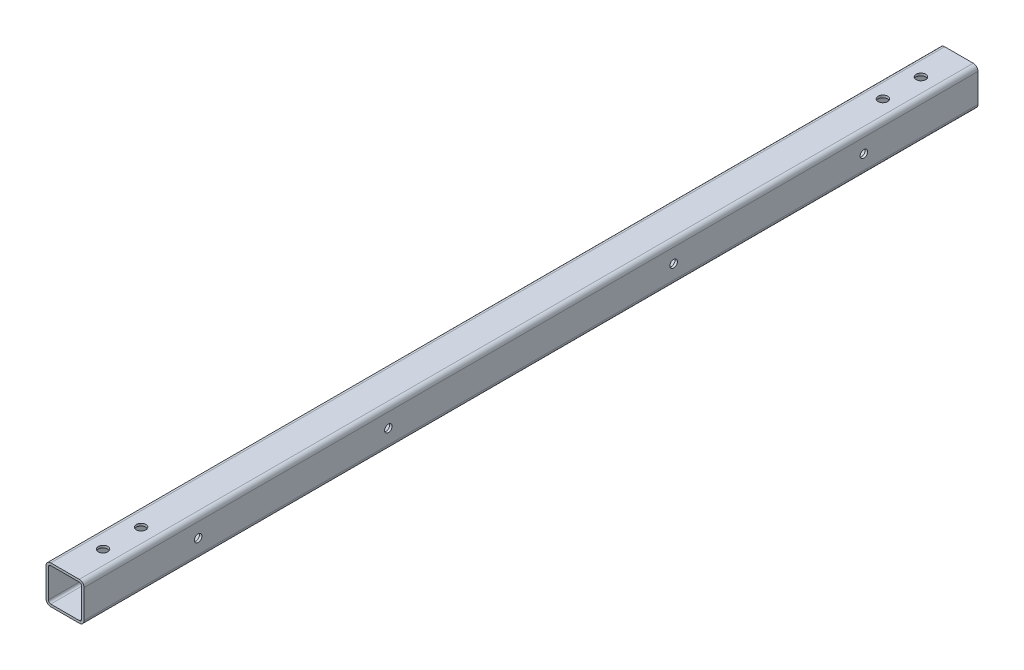
from build123d import *

# Parameters (mm, degrees)
SKETCH1_W          = 25.4
SKETCH1_H          = 25.4
BASE_EXTRUDE_DEPTH = 298.45
FILLET1_R          = 3.175
SHELL1_T           = -1.5875
SKETCH4_R          = 3.175
CUT_EXTRUDE1_DEPTH = 26.4
CUT_EXTRUDE3_REACH = 3.588
SKETCH6_R          = 2.5


with BuildPart() as part:
    # Sketch1 → Base-Extrude (new body, symmetric)
    with BuildSketch(Plane.XY):
        Rectangle(SKETCH1_W, SKETCH1_H)
    extrude(amount=BASE_EXTRUDE_DEPTH, both=True)

    # Fillet1
    fillet1_edges = [part.edges().sort_by_distance(p)[0] for p in [
        (-12.7, 12.7, 0),
        (12.7, 12.7, 0),
        (12.7, -12.7, 0),
        (-12.7, -12.7, 0),
    ]]
    fillet(fillet1_edges, radius=FILLET1_R)

    # Shell1
    shell1_openings = [part.faces().sort_by_distance(p)[0] for p in [
        (0, 0, 298.45),
        (0, 0, -298.45),
    ]]
    offset(amount=SHELL1_T, openings=shell1_openings, kind=Kind.INTERSECTION)

    # Sketch4 → Cut-Extrude1 (cut, through all)
    with BuildSketch(Plane.XZ.offset(12.7)):
        with Locations((0, 273.05)):
            Circle(SKETCH4_R)
        with Locations((0, 247.65)):
            Circle(SKETCH4_R)
        with Locations((0, -247.65)):
            Circle(SKETCH4_R)
        with Locations((0, -273.05)):
            Circle(SKETCH4_R)
    extrude(amount=-CUT_EXTRUDE1_DEPTH, mode=Mode.SUBTRACT)

    # Sketch6 → Cut-Extrude3 (cut, up to next)
    with BuildSketch(Plane.ZY.offset(-11.1125), mode=Mode.PRIVATE) as cut_extrude3_sk1:
        with Locations((-95.25, 0)):
            Circle(SKETCH6_R)
    cut_extrude3_tool1 = extrude(cut_extrude3_sk1.sketch, amount=-CUT_EXTRUDE3_REACH, mode=Mode.PRIVATE) & part.part
    add(cut_extrude3_tool1.solids().sort_by_distance((11.1125, 0, -95.25))[0], mode=Mode.SUBTRACT)
    # Sketch6 → Cut-Extrude3 (cut, up to next)
    with BuildSketch(Plane.ZY.offset(-11.1125), mode=Mode.PRIVATE) as cut_extrude3_sk2:
        with Locations((-222.25, 0)):
            Circle(SKETCH6_R)
    cut_extrude3_tool2 = extrude(cut_extrude3_sk2.sketch, amount=-CUT_EXTRUDE3_REACH, mode=Mode.PRIVATE) & part.part
    add(cut_extrude3_tool2.solids().sort_by_distance((11.1125, 0, -222.25))[0], mode=Mode.SUBTRACT)
    # Sketch6 → Cut-Extrude3 (cut, up to next)
    with BuildSketch(Plane.ZY.offset(-11.1125), mode=Mode.PRIVATE) as cut_extrude3_sk3:
        with Locations((222.25, 0)):
            Circle(SKETCH6_R)
    cut_extrude3_tool3 = extrude(cut_extrude3_sk3.sketch, amount=-CUT_EXTRUDE3_REACH, mode=Mode.PRIVATE) & part.part
    add(cut_extrude3_tool3.solids().sort_by_distance((11.1125, 0, 222.25))[0], mode=Mode.SUBTRACT)
    # Sketch6 → Cut-Extrude3 (cut, up to next)
    with BuildSketch(Plane.ZY.offset(-11.1125), mode=Mode.PRIVATE) as cut_extrude3_sk4:
        with Locations((95.25, 0)):
            Circle(SKETCH6_R)
    cut_extrude3_tool4 = extrude(cut_extrude3_sk4.sketch, amount=-CUT_EXTRUDE3_REACH, mode=Mode.PRIVATE) & part.part
    add(cut_extrude3_tool4.solids().sort_by_distance((11.1125, 0, 95.25))[0], mode=Mode.SUBTRACT)


solid = part.part
